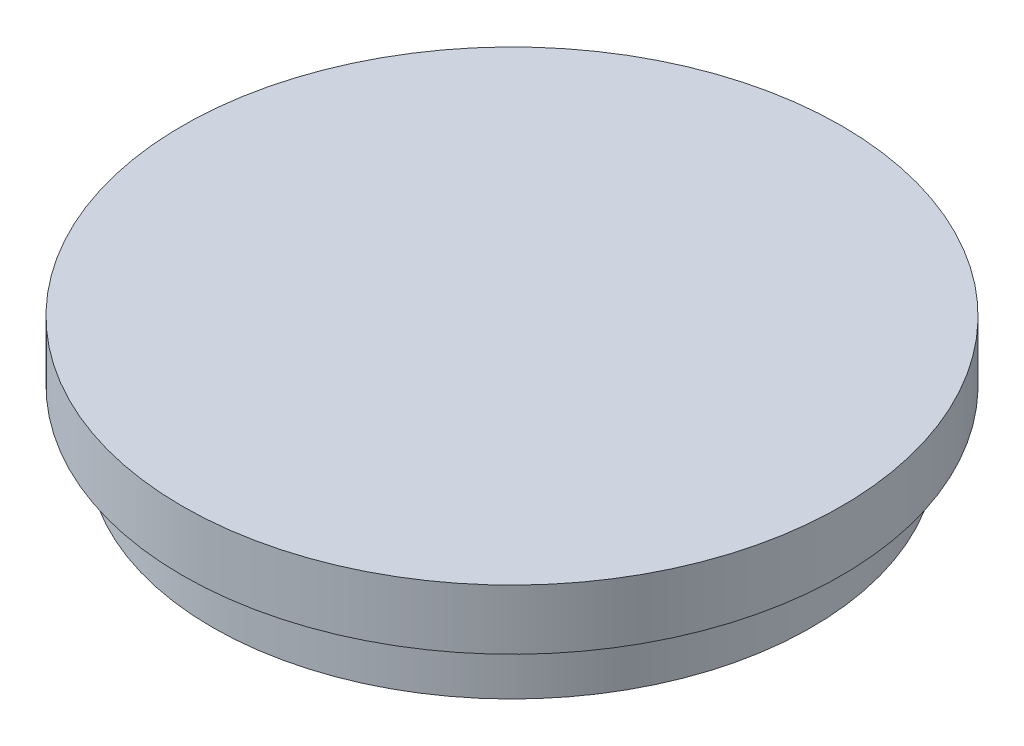
from build123d import *

# Parameters (mm, degrees)
SKETCH1_R           = 10
BOSS_EXTRUDE1_DEPTH = 2
SKETCH2_R           = 11
BOSS_EXTRUDE2_DEPTH = 2


with BuildPart() as part:
    # Sketch1 → Boss-Extrude1 (new body)
    with BuildSketch(Plane(origin=(0, 0, 0), x_dir=(1, 0, 0), z_dir=(0, 1, 0))):
        Circle(SKETCH1_R)
    extrude(amount=BOSS_EXTRUDE1_DEPTH)

    # Sketch2 → Boss-Extrude2 (add)
    with BuildSketch(Plane(origin=(0, 2, 0), x_dir=(1, 0, 0), z_dir=(0, 1, 0))):
        Circle(SKETCH2_R)
    extrude(amount=BOSS_EXTRUDE2_DEPTH)


solid = part.part
